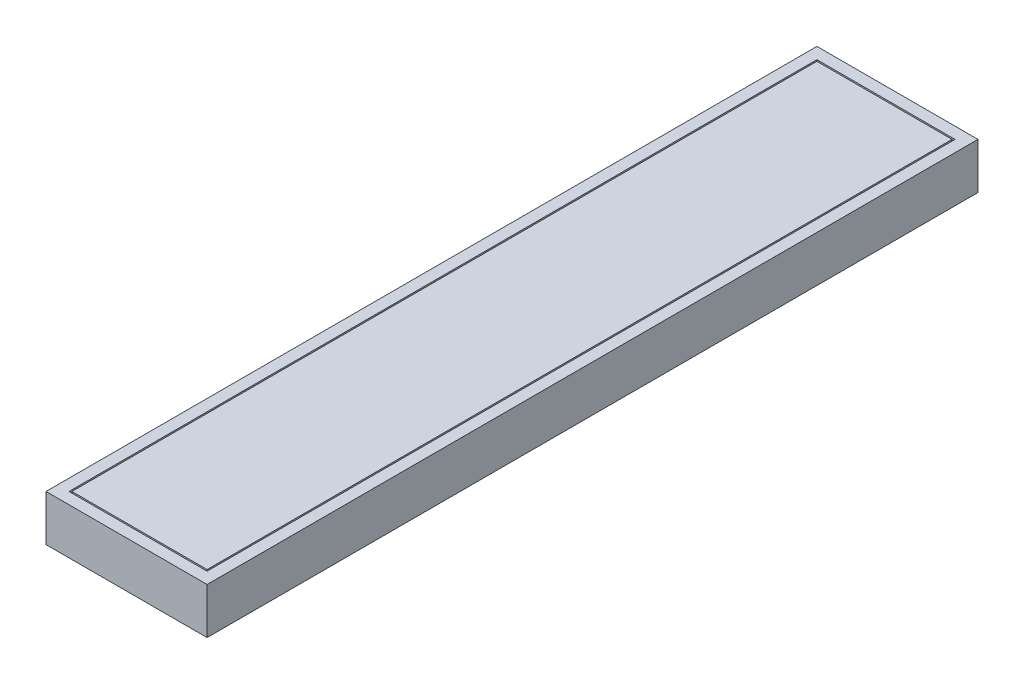
from build123d import *

# Parameters (mm, degrees)
SKETCH1_W           = 280
SKETCH1_H           = 1340
BOSS_EXTRUDE1_DEPTH = 80
SKETCH2_W           = 240
SKETCH2_H           = 1300
CUT_EXTRUDE1_DEPTH  = 11
SKETCH3_W           = 235
SKETCH3_H           = 1295
BOSS_EXTRUDE2_DEPTH = 11


with BuildPart() as part:
    # Sketch1 → Boss-Extrude1 (new body)
    with BuildSketch(Plane.XZ.offset(60)):
        with Locations((0, 670)):
            Rectangle(SKETCH1_W, SKETCH1_H)
    extrude(amount=-BOSS_EXTRUDE1_DEPTH)

    # Sketch2 → Cut-Extrude1 (cut)
    with BuildSketch(Plane(origin=(0, 20, 0), x_dir=(-1, 0, 0), z_dir=(0, 1, 0))):
        with Locations((0, 670)):
            Rectangle(SKETCH2_W, SKETCH2_H)
    extrude(amount=-CUT_EXTRUDE1_DEPTH, mode=Mode.SUBTRACT)

    # Sketch3 → Boss-Extrude2 (add)
    with BuildSketch(Plane(origin=(0, 9, 0), x_dir=(-1, 0, 0), z_dir=(0, 1, 0))):
        with Locations((0, 670)):
            Rectangle(SKETCH3_W, SKETCH3_H)
    extrude(amount=BOSS_EXTRUDE2_DEPTH)


solid = part.part
